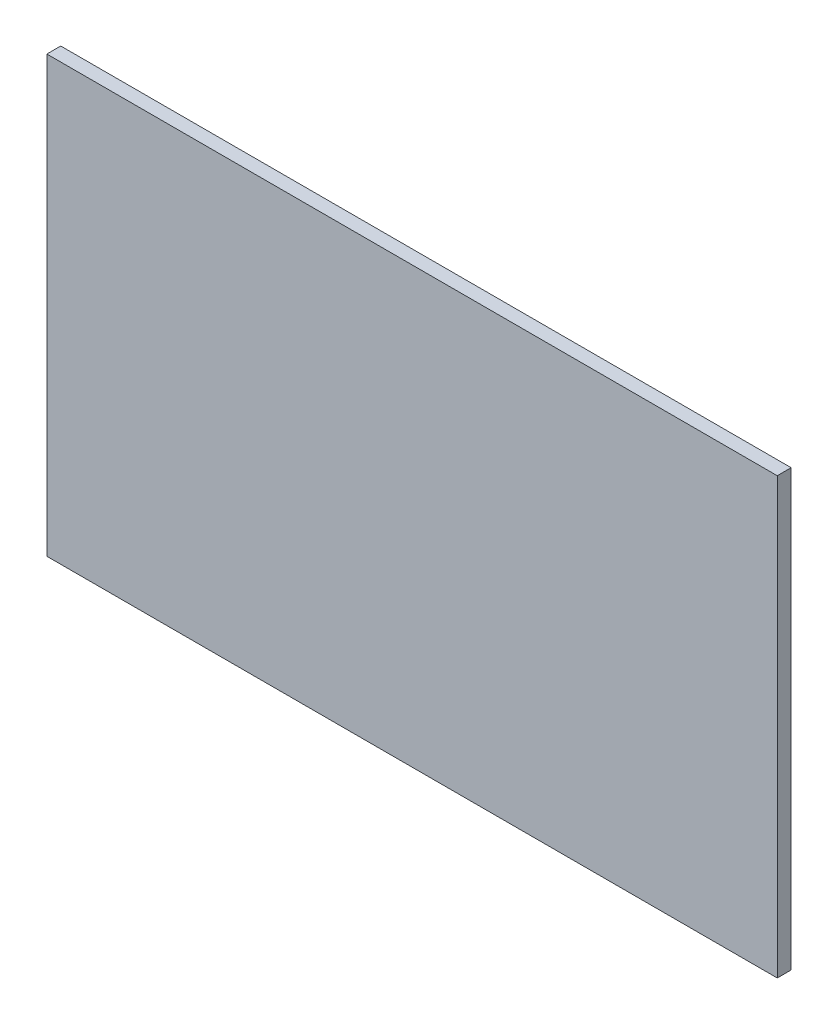
from build123d import *

# Parameters (mm, degrees)
SKETCH1_W           = 947
SKETCH1_H           = 564
BOSS_EXTRUDE1_DEPTH = 18


with BuildPart() as part:
    # Sketch1 → Boss-Extrude1 (new body)
    with BuildSketch(Plane.XY):
        Rectangle(SKETCH1_W, SKETCH1_H)
    extrude(amount=BOSS_EXTRUDE1_DEPTH)


solid = part.part
